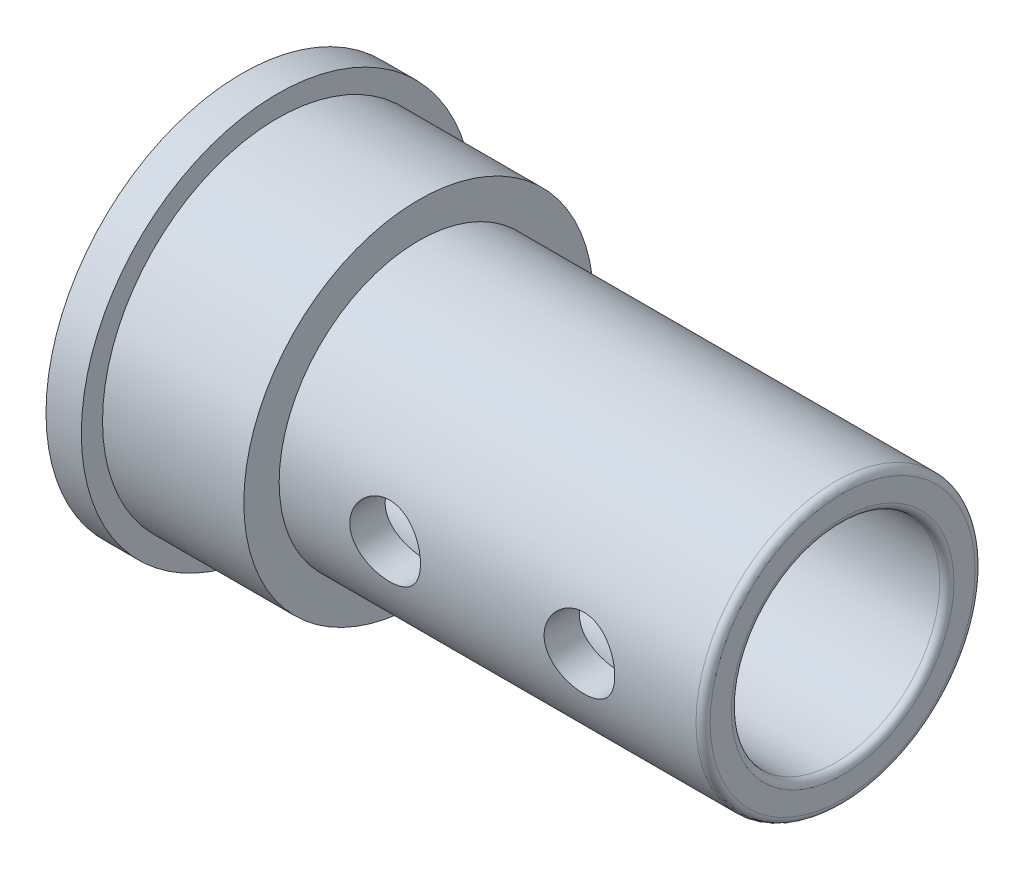
from build123d import *

# Parameters (mm, degrees)
ESQUISSE4_W               = 1
ESQUISSE4_H               = 5.55
D_GAGEMENT_M21_AT_2_COUNT = 2
D_GAGEMENT_M21_AT_2_PITCH = 5.5


with BuildPart() as part:
    # Esquisse1 → Révolution1 (revolve)
    with BuildSketch(Plane.XY):
        with BuildLine():
            Line((0, 4.05), (0, 5.55))
            Line((0, 5.55), (1, 5.55))
            Line((1, 5.55), (1, 4.95))
            Line((1, 4.95), (5, 4.95))
            Line((5, 4.95), (5, 3.95))
            Line((5, 3.95), (16.8, 3.95))
            ThreePointArc((16.8, 3.95), (16.941421356, 3.891421356), (17, 3.75))
            Line((17, 3.75), (17, 3.15))
            ThreePointArc((17, 3.15), (16.941421356, 3.008578644), (16.8, 2.95))
            Line((16.8, 2.95), (1, 2.95))
            Line((1, 2.95), (1, 4.05))
            Line((1, 4.05), (0, 4.05))
        make_face()
    revolve(axis=Axis((-11.300588411, 0, 0), (1, 0, 0)))

    # Esquisse4 → Dégagement M21 (revolve, cut)
    with BuildSketch(Plane.YZ.offset(8)):
        with Locations((0.5, 2.775)):
            Rectangle(ESQUISSE4_W, ESQUISSE4_H)
    d_gagement_m21 = revolve(axis=Axis((8, 0, -6.35), (0, 0, 1)), mode=Mode.SUBTRACT)

    # Dégagement M21 at 2: Dégagement M21 ×2
    with Locations(*[(i * D_GAGEMENT_M21_AT_2_PITCH, 0, 0) for i in range(1, D_GAGEMENT_M21_AT_2_COUNT)]):
        add(d_gagement_m21, mode=Mode.SUBTRACT)


solid = part.part
